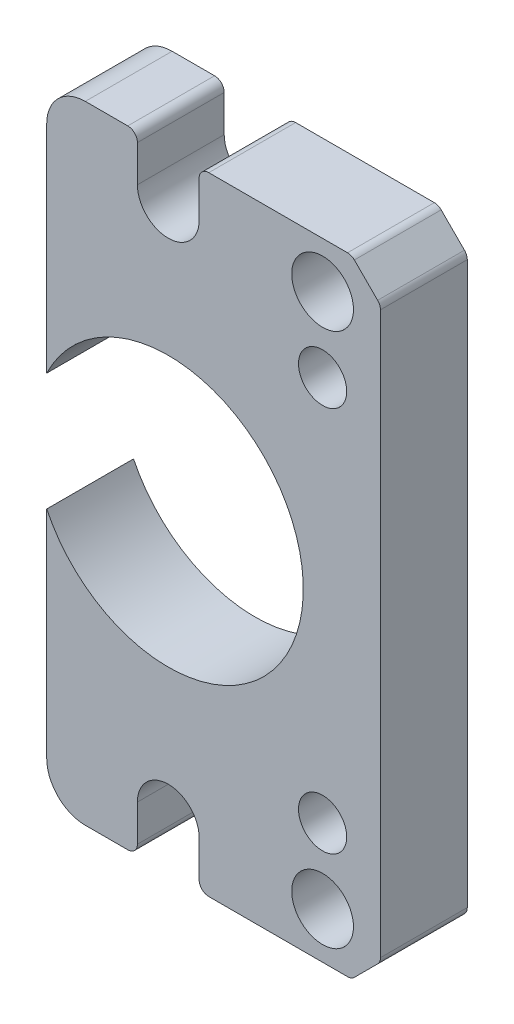
from build123d import *

# Parameters (mm, degrees)
ESBO_O1_R                = 1.25
ESBO_O1_R_2              = 1.6
ESBO_O1_R_3              = 7
RESSALTO_EXTRUS_O1_DEPTH = 4.5
ESBO_O2_W                = 9.082800448
ESBO_O2_H                = 32.5
CORTE_EXTRUS_O1_DEPTH    = 5.5
FILETE1_R                = 2


with BuildPart() as part:
    # Esboço1 → Ressalto-extrusão1 (new body)
    with BuildSketch(Plane(origin=(0, 0, -4.5), x_dir=(-1, 0, 0), z_dir=(0, 0, -1))):
        with BuildLine():
            Line((-10.853553391, -14.896446609), (-9.646446609, -16.103553391))
            ThreePointArc((-9.646446609, -16.103553391), (-9.484234935, -16.211939766), (-9.292893219, -16.25))
            Line((-9.292893219, -16.25), (-2.1, -16.25))
            ThreePointArc((-2.1, -16.25), (-1.746446609, -16.103553391), (-1.6, -15.75))
            Line((-1.6, -15.75), (-1.6, -13.856406461))
            ThreePointArc((-1.6, -13.856406461), (0, -12.256406461), (1.6, -13.856406461))
            Line((1.6, -13.856406461), (1.6, -15.75))
            ThreePointArc((1.6, -15.75), (1.746446609, -16.103553391), (2.1, -16.25))
            Line((2.1, -16.25), (9.292893219, -16.25))
            ThreePointArc((9.292893219, -16.25), (9.484234935, -16.211939766), (9.646446609, -16.103553391))
            Line((9.646446609, -16.103553391), (10.853553391, -14.896446609))
            ThreePointArc((10.853553391, -14.896446609), (10.961939766, -14.734234935), (11, -14.542893219))
            Line((11, -14.542893219), (11, 14.542893219))
            ThreePointArc((11, 14.542893219), (10.961939766, 14.734234935), (10.853553391, 14.896446609))
            Line((10.853553391, 14.896446609), (9.646446609, 16.103553391))
            ThreePointArc((9.646446609, 16.103553391), (9.484234935, 16.211939766), (9.292893219, 16.25))
            Line((9.292893219, 16.25), (2.1, 16.25))
            ThreePointArc((2.1, 16.25), (1.746446609, 16.103553391), (1.6, 15.75))
            Line((1.6, 15.75), (1.6, 13.856406461))
            ThreePointArc((1.6, 13.856406461), (0, 12.256406461), (-1.6, 13.856406461))
            Line((-1.6, 13.856406461), (-1.6, 15.75))
            ThreePointArc((-1.6, 15.75), (-1.746446609, 16.103553391), (-2.1, 16.25))
            Line((-2.1, 16.25), (-9.292893219, 16.25))
            ThreePointArc((-9.292893219, 16.25), (-9.484234935, 16.211939766), (-9.646446609, 16.103553391))
            Line((-9.646446609, 16.103553391), (-10.853553391, 14.896446609))
            ThreePointArc((-10.853553391, 14.896446609), (-10.961939766, 14.734234935), (-11, 14.542893219))
            Line((-11, 14.542893219), (-11, -14.542893219))
            ThreePointArc((-11, -14.542893219), (-10.961939766, -14.734234935), (-10.853553391, -14.896446609))
        make_face()
        with Locations((-8, -10)):
            Circle(ESBO_O1_R, mode=Mode.SUBTRACT)
        with Locations((8, -10)):
            Circle(ESBO_O1_R, mode=Mode.SUBTRACT)
        with Locations((8, 10)):
            Circle(ESBO_O1_R, mode=Mode.SUBTRACT)
        with Locations((-8, 10)):
            Circle(ESBO_O1_R, mode=Mode.SUBTRACT)
        with Locations((-8, -13.85640646)):
            Circle(ESBO_O1_R_2, mode=Mode.SUBTRACT)
        with Locations((8, -13.85640646)):
            Circle(ESBO_O1_R_2, mode=Mode.SUBTRACT)
        with Locations((8, 13.85640646)):
            Circle(ESBO_O1_R_2, mode=Mode.SUBTRACT)
        with Locations((-8, 13.85640646)):
            Circle(ESBO_O1_R_2, mode=Mode.SUBTRACT)
        Circle(ESBO_O1_R_3, mode=Mode.SUBTRACT)
    extrude(amount=-RESSALTO_EXTRUS_O1_DEPTH)

    # Esboço2 → Corte-extrusão1 (cut, through all)
    with BuildSketch(Plane.XY):
        with Locations((-10.842301115, 0)):
            Rectangle(ESBO_O2_W, ESBO_O2_H)
    extrude(amount=-CORTE_EXTRUS_O1_DEPTH, mode=Mode.SUBTRACT)

    # Filete1
    filete1_edges = [part.edges().sort_by_distance(p)[0] for p in [
        (-6.300900891, 16.25, -2.25),
        (-6.300900891, -16.25, -2.25),
    ]]
    fillet(filete1_edges, radius=FILETE1_R)


solid = part.part
